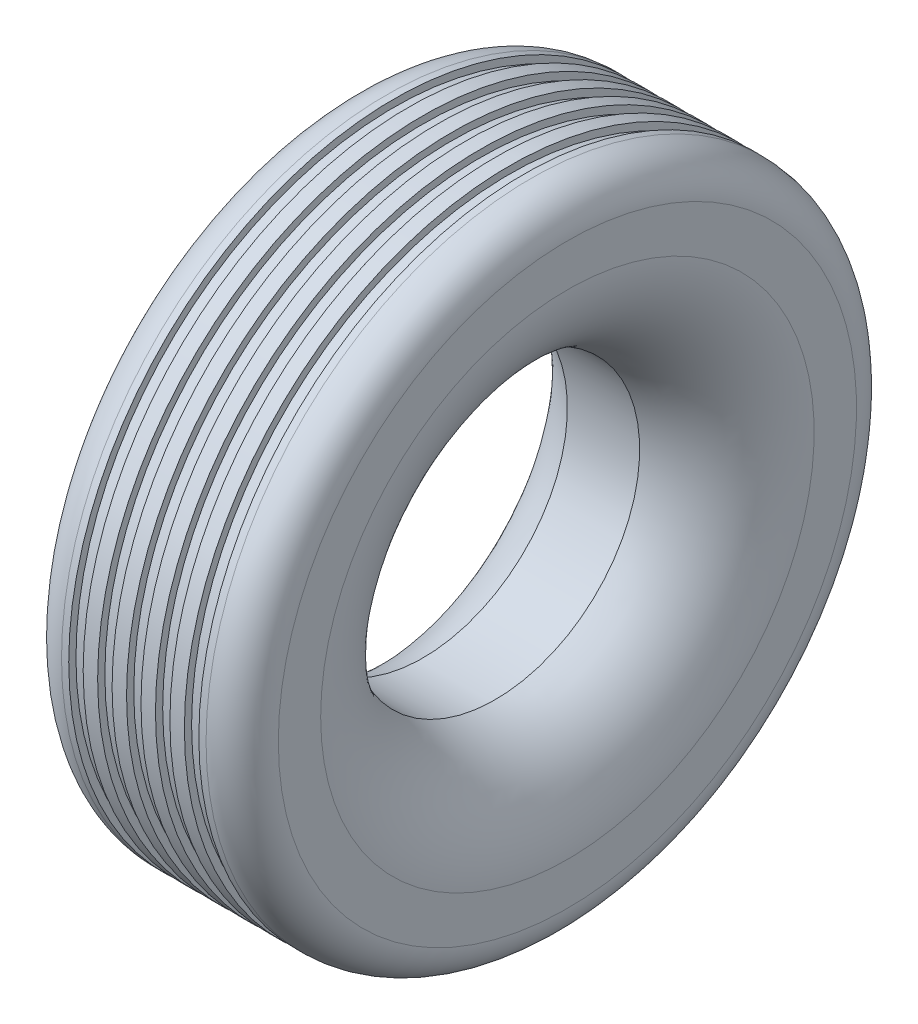
from build123d import *

# Parameters (mm, degrees)
SKETCH5_R          = 200
CUT_EXTRUDE3_DEPTH = 201


with BuildPart() as part:
    # Sketch2 → Revolve2 (revolve)
    with BuildSketch(Plane.XY):
        with BuildLine():
            Line((60, 450), (60, 440))
            Line((60, 440), (80, 440))
            Line((80, 440), (80, 450))
            Line((80, 450), (100, 450))
            Line((100, 450), (100, 440))
            Line((100, 440), (120, 440))
            Line((120, 440), (120, 450))
            Line((120, 450), (140, 450))
            Line((140, 450), (140, 440))
            Line((140, 440), (160, 440))
            Line((160, 440), (160, 450))
            Line((160, 450), (180, 450))
            Line((180, 450), (180, 440))
            Line((180, 440), (200, 440))
            Line((200, 440), (200, 450))
            Line((200, 450), (220, 450))
            Line((220, 450), (220, 440))
            Line((220, 440), (240, 440))
            Line((240, 440), (240, 450))
            Line((240, 450), (250, 450))
            ThreePointArc((250, 450), (285.355339059, 435.355339059), (300, 400))
            Line((300, 400), (300, 341.421356237))
            ThreePointArc((300, 341.421356237), (272.474487139, 254.818815859), (200, 200))
            Line((200, 200), (200, 0))
            Line((200, 0), (100, 0))
            Line((100, 0), (100, 200))
            ThreePointArc((100, 200), (27.525512861, 254.818815859), (0, 341.421356237))
            Line((0, 341.421356237), (0, 400))
            ThreePointArc((0, 400), (14.644660941, 435.355339059), (50, 450))
            Line((50, 450), (60, 450))
        make_face()
    revolve(axis=Axis((100, 0, 0), (1, 0, 0)))

    # Sketch5 → Cut-Extrude3 (cut, through all)
    with BuildSketch(Plane.ZY.offset(-100)):
        Circle(SKETCH5_R)
    extrude(amount=-CUT_EXTRUDE3_DEPTH, mode=Mode.SUBTRACT)


solid = part.part
